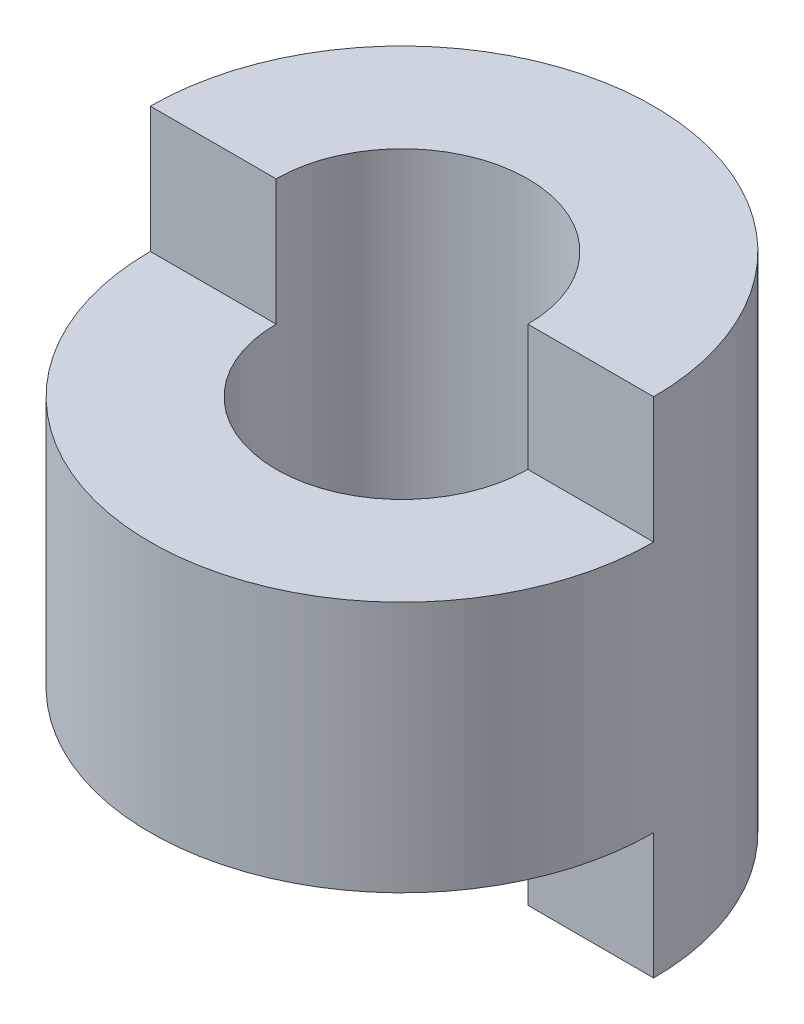
from build123d import *

# Parameters (mm, degrees)
SKETCH1_W          = 10
SKETCH1_H          = 20
SKETCH2_R          = 5
CUT_EXTRUDE1_DEPTH = 20
CUT_EXTRUDE2_DEPTH = 5
CUT_EXTRUDE4_DEPTH = 5


with BuildPart() as part:
    # Sketch1 → Revolve1 (revolve)
    with BuildSketch(Plane.XY):
        with Locations((5, 10)):
            Rectangle(SKETCH1_W, SKETCH1_H)
    revolve(axis=Axis((0, 0, 0), (0, 1, 0)))

    # Sketch2 → Cut-Extrude1 (cut)
    with BuildSketch(Plane(origin=(0, 20, 0), x_dir=(1, 0, 0), z_dir=(0, 1, 0))):
        Circle(SKETCH2_R)
    extrude(amount=-CUT_EXTRUDE1_DEPTH, mode=Mode.SUBTRACT)

    # Sketch3 → Cut-Extrude2 (cut)
    with BuildSketch(Plane(origin=(0, 20, 0), x_dir=(1, 0, 0), z_dir=(0, 1, 0))):
        with BuildLine():
            Line((-10, 0), (-5, 0))
            ThreePointArc((-5, 0), (0, -5), (5, 0))
            Line((5, 0), (10, 0))
            ThreePointArc((10, 0), (0, -10), (-10, 0))
        make_face()
    extrude(amount=-CUT_EXTRUDE2_DEPTH, mode=Mode.SUBTRACT)

    # Sketch4 → Cut-Extrude4 (cut)
    with BuildSketch(Plane.XZ):
        with BuildLine():
            Line((-10, 0), (-5, 0))
            ThreePointArc((-5, 0), (0, 5), (5, 0))
            Line((5, 0), (10, 0))
            ThreePointArc((10, 0), (0, 10), (-10, 0))
        make_face()
    extrude(amount=-CUT_EXTRUDE4_DEPTH, mode=Mode.SUBTRACT)


solid = part.part
